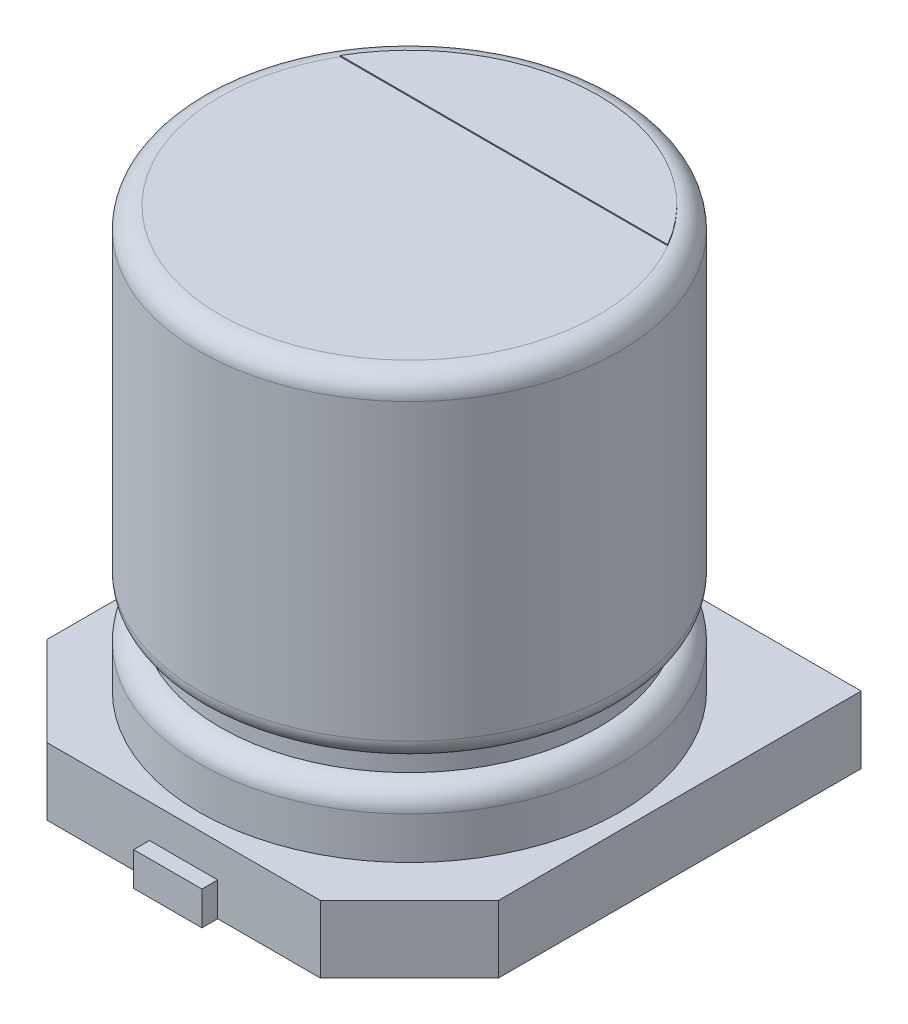
from build123d import *

# Parameters (mm, degrees)
BOSS_EXTRUDE1_DEPTH = 0.01
BOSS_EXTRUDE2_DEPTH = 0.64
CUT_EXTRUDE1_START  = 0.64
CUT_EXTRUDE1_DEPTH  = 0.32
SKETCH4_W           = 0.65
SKETCH4_H           = 1.8
BOSS_EXTRUDE3_DEPTH = 0.32


with BuildPart() as part:
    # Sketch1 → Revolve1 (revolve)
    with BuildSketch(Plane.XY):
        with BuildLine():
            Line((0, 4), (-1.8, 4))
            ThreePointArc((-1.8, 4), (-1.941421356, 3.941421356), (-2, 3.8))
            Line((-2, 3.8), (-2, 1))
            ThreePointArc((-2, 1), (-1.941421356, 0.858578644), (-1.8, 0.8))
            Line((-1.8, 0.8), (-1.8, 0.6))
            ThreePointArc((-1.8, 0.6), (-1.941421356, 0.541421356), (-2, 0.4))
            Line((-2, 0.4), (-2, 0))
            Line((-2, 0), (0, 0))
            Line((0, 0), (0, 4))
        make_face()
    revolve(axis=Axis((0, 8.082229881, 0), (0, -1, 0)))

    # Sketch2 → Boss-Extrude1 (add)
    with BuildSketch(Plane(origin=(0, 4, 0), x_dir=(1, 0, 0), z_dir=(0, 1, 0))):
        with BuildLine():
            Line((-1.558845727, 0.9), (1.558845727, 0.9))
            ThreePointArc((1.558845727, 0.9), (0, 1.8), (-1.558845727, 0.9))
        make_face()
    extrude(amount=BOSS_EXTRUDE1_DEPTH)

    # Sketch3 → Boss-Extrude2 (add)
    with BuildSketch(Plane(origin=(0, 0, 0), x_dir=(-1, 0, 0), z_dir=(0, -1, 0))):
        Polygon((1.301471863, -2.15), (2.15, -1.301471863), (2.15, 2.15), (-2.15, 2.15), (-2.15, -1.301471863), (-1.301471863, -2.15), align=None)
    extrude(amount=BOSS_EXTRUDE2_DEPTH)

    # Sketch3_3 → Cut-Extrude1 (cut)
    with BuildSketch(Plane(origin=(0, 0, 0), x_dir=(-1, 0, 0), z_dir=(0, -1, 0)).offset(CUT_EXTRUDE1_START)):
        with BuildLine():
            Line((0.325, 0.5), (0.325, 1.973417087))
            ThreePointArc((0.325, 1.973417087), (0, 2), (-0.325, 1.973417087))
            Line((-0.325, 1.973417087), (-0.325, 0.5))
            Line((-0.325, 0.5), (0.325, 0.5))
        make_face()
        with BuildLine():
            ThreePointArc((-0.325, -1.973417087), (0, -2), (0.325, -1.973417087))
            Line((0.325, -1.973417087), (0.325, -0.5))
            Line((0.325, -0.5), (-0.325, -0.5))
            Line((-0.325, -0.5), (-0.325, -1.973417087))
        make_face()
        with BuildLine():
            Line((0.325, 1.973417087), (0.325, 2.15))
            Line((0.325, 2.15), (-0.325, 2.15))
            Line((-0.325, 2.15), (-0.325, 1.973417087))
            ThreePointArc((-0.325, 1.973417087), (0, 2), (0.325, 1.973417087))
        make_face()
        with BuildLine():
            Line((-0.325, -2.15), (0.325, -2.15))
            Line((0.325, -2.15), (0.325, -1.973417087))
            ThreePointArc((0.325, -1.973417087), (0, -2), (-0.325, -1.973417087))
            Line((-0.325, -1.973417087), (-0.325, -2.15))
        make_face()
    extrude(amount=-CUT_EXTRUDE1_DEPTH, mode=Mode.SUBTRACT)

    # Sketch4 → Boss-Extrude3 (add)
    with BuildSketch(Plane.XZ.offset(0.32)):
        with Locations((0, -1.4)):
            Rectangle(SKETCH4_W, SKETCH4_H)
        with Locations((0, 1.4)):
            Rectangle(SKETCH4_W, SKETCH4_H)
    extrude(amount=BOSS_EXTRUDE3_DEPTH)


solid = part.part
